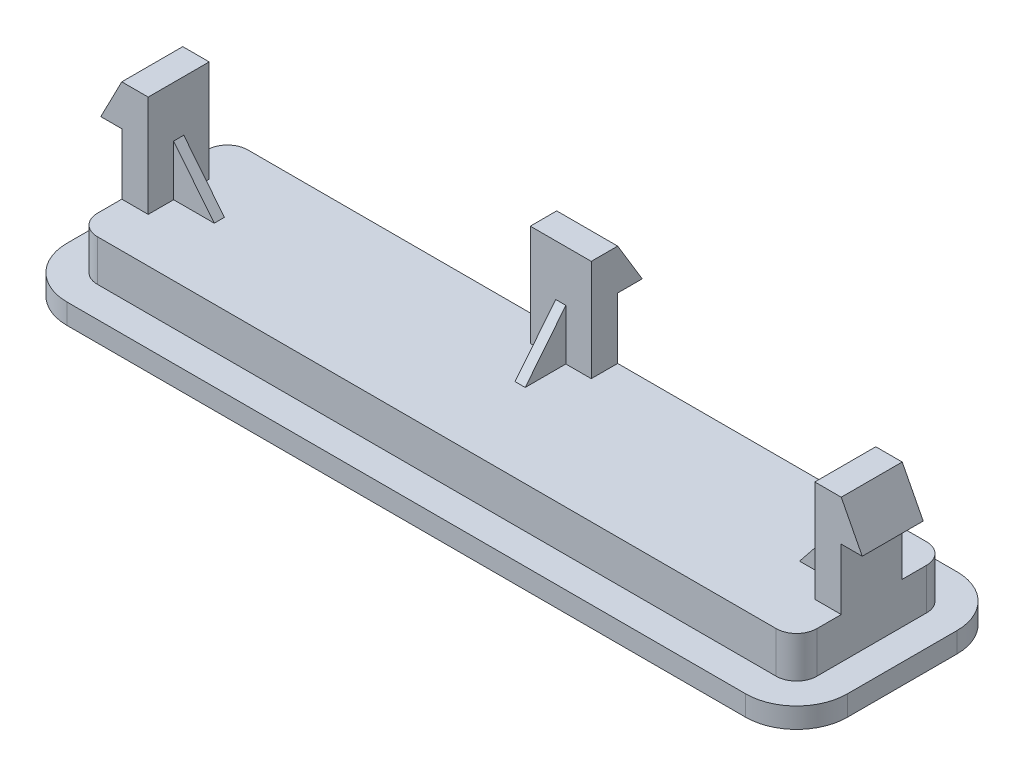
from build123d import *

# Parameters (mm, degrees)
BOSS_EXTRUDE1_DEPTH = 3.03
BOSS_EXTRUDE2_DEPTH = 1
SKETCH3_W           = 1.3
SKETCH3_H           = 3
SKETCH3_W_2         = 1.5
SKETCH3_H_2         = 1.3
BOSS_EXTRUDE3_DEPTH = 5
BOSS_EXTRUDE4_DEPTH = 3
BOSS_EXTRUDE5_DEPTH = 1.5
SKETCH9_W           = 0.5
SKETCH9_H           = 2.5
BOSS_EXTRUDE6_DEPTH = 2
CUT_EXTRUDE1_DEPTH  = 0.5
SKETCH11_W          = 0.25
SKETCH11_H          = 2.5
BOSS_EXTRUDE7_DEPTH = 2
CUT_EXTRUDE2_DEPTH  = 0.25


with BuildPart() as part:
    # Sketch1 → Boss-Extrude1 (new body)
    with BuildSketch(Plane(origin=(0, 0, 0), x_dir=(1, 0, 0), z_dir=(0, 1, 0))):
        with BuildLine():
            Line((-16.7, -3.7), (16.7, -3.7))
            ThreePointArc((16.7, -3.7), (17.407106781, -3.407106781), (17.7, -2.7))
            Line((17.7, -2.7), (17.7, 2.7))
            ThreePointArc((17.7, 2.7), (17.407106781, 3.407106781), (16.7, 3.7))
            Line((16.7, 3.7), (-16.7, 3.7))
            ThreePointArc((-16.7, 3.7), (-17.407106781, 3.407106781), (-17.7, 2.7))
            Line((-17.7, 2.7), (-17.7, -2.7))
            ThreePointArc((-17.7, -2.7), (-17.407106781, -3.407106781), (-16.7, -3.7))
        make_face()
    extrude(amount=BOSS_EXTRUDE1_DEPTH)

    # Sketch2 → Boss-Extrude2 (add)
    with BuildSketch(Plane.XZ):
        with BuildLine():
            Line((16.7, 5.2), (-16.7, 5.2))
            ThreePointArc((-16.7, 5.2), (-18.467766953, 4.467766953), (-19.2, 2.7))
            Line((-19.2, 2.7), (-19.2, -2.7))
            ThreePointArc((-19.2, -2.7), (-18.467766953, -4.467766953), (-16.7, -5.2))
            Line((-16.7, -5.2), (16.7, -5.2))
            ThreePointArc((16.7, -5.2), (18.467766953, -4.467766953), (19.2, -2.7))
            Line((19.2, -2.7), (19.2, 2.7))
            ThreePointArc((19.2, 2.7), (18.467766953, 4.467766953), (16.7, 5.2))
        make_face()
    extrude(amount=-BOSS_EXTRUDE2_DEPTH)

    # Sketch3 → Boss-Extrude3 (add)
    with BuildSketch(Plane(origin=(0, 3.03, 0), x_dir=(1, 0, 0), z_dir=(0, 1, 0))):
        with Locations((-17.05, 0)):
            Rectangle(SKETCH3_W, SKETCH3_H)
        with Locations((-0.75, 3.05)):
            Rectangle(SKETCH3_W_2, SKETCH3_H_2)
    boss_extrude3 = extrude(amount=BOSS_EXTRUDE3_DEPTH)

    # Sketch5 → Boss-Extrude4 (add)
    with BuildSketch(Plane.XY.offset(1.5)):
        Polygon((-17.7, 8.03), (-18.733327763, 6.03), (-17.7, 6.03), align=None)
    boss_extrude4 = extrude(amount=-BOSS_EXTRUDE4_DEPTH)

    # Sketch8 → Boss-Extrude5 (add)
    with BuildSketch(Plane.ZY.offset(1.5)):
        Polygon((-3.7, 8.03), (-4.910348547, 6.03), (-3.7, 6.03), align=None)
    boss_extrude5 = extrude(amount=-BOSS_EXTRUDE5_DEPTH)

    # Sketch9 → Boss-Extrude6 (add)
    with BuildSketch(Plane(origin=(-16.4, 0, 0), x_dir=(0, 0, -1), z_dir=(1, 0, 0))):
        with Locations((0, 4.28)):
            Rectangle(SKETCH9_W, SKETCH9_H)
    boss_extrude6 = extrude(amount=BOSS_EXTRUDE6_DEPTH)

    # Sketch10 → Cut-Extrude1 (cut)
    with BuildSketch(Plane.XY.offset(0.25)):
        Polygon((-16.4, 5.53), (-14.4, 3.03), (-14.4, 5.53), align=None)
    cut_extrude1 = extrude(amount=-CUT_EXTRUDE1_DEPTH, mode=Mode.SUBTRACT)

    # Sketch11 → Boss-Extrude7 (add)
    with BuildSketch(Plane.XY.offset(-2.4)):
        with Locations((-0.125, 4.28)):
            Rectangle(SKETCH11_W, SKETCH11_H)
    boss_extrude7 = extrude(amount=BOSS_EXTRUDE7_DEPTH)

    # Sketch12 → Cut-Extrude2 (cut)
    with BuildSketch(Plane.ZY.offset(0.25)):
        Polygon((-2.4, 5.53), (-0.4, 3.03), (-0.4, 5.53), align=None)
    cut_extrude2 = extrude(amount=-CUT_EXTRUDE2_DEPTH, mode=Mode.SUBTRACT)

    # Mirror1: Boss-Extrude3, Boss-Extrude4, Boss-Extrude5, Boss-Extrude6, Cut-Extrude1, Boss-Extrude7, Cut-Extrude2 across plane
    add(boss_extrude3.mirror(Plane(origin=(0, 0, 0), x_dir=(0, 0, 1), z_dir=(1, 0, 0))))
    add(boss_extrude4.mirror(Plane(origin=(0, 0, 0), x_dir=(0, 0, 1), z_dir=(1, 0, 0))))
    add(boss_extrude5.mirror(Plane(origin=(0, 0, 0), x_dir=(0, 0, 1), z_dir=(1, 0, 0))))
    add(boss_extrude6.mirror(Plane(origin=(0, 0, 0), x_dir=(0, 0, 1), z_dir=(1, 0, 0))))
    add(cut_extrude1.mirror(Plane(origin=(0, 0, 0), x_dir=(0, 0, 1), z_dir=(1, 0, 0))), mode=Mode.SUBTRACT)
    add(boss_extrude7.mirror(Plane(origin=(0, 0, 0), x_dir=(0, 0, 1), z_dir=(1, 0, 0))))
    add(cut_extrude2.mirror(Plane(origin=(0, 0, 0), x_dir=(0, 0, 1), z_dir=(1, 0, 0))), mode=Mode.SUBTRACT)


solid = part.part
